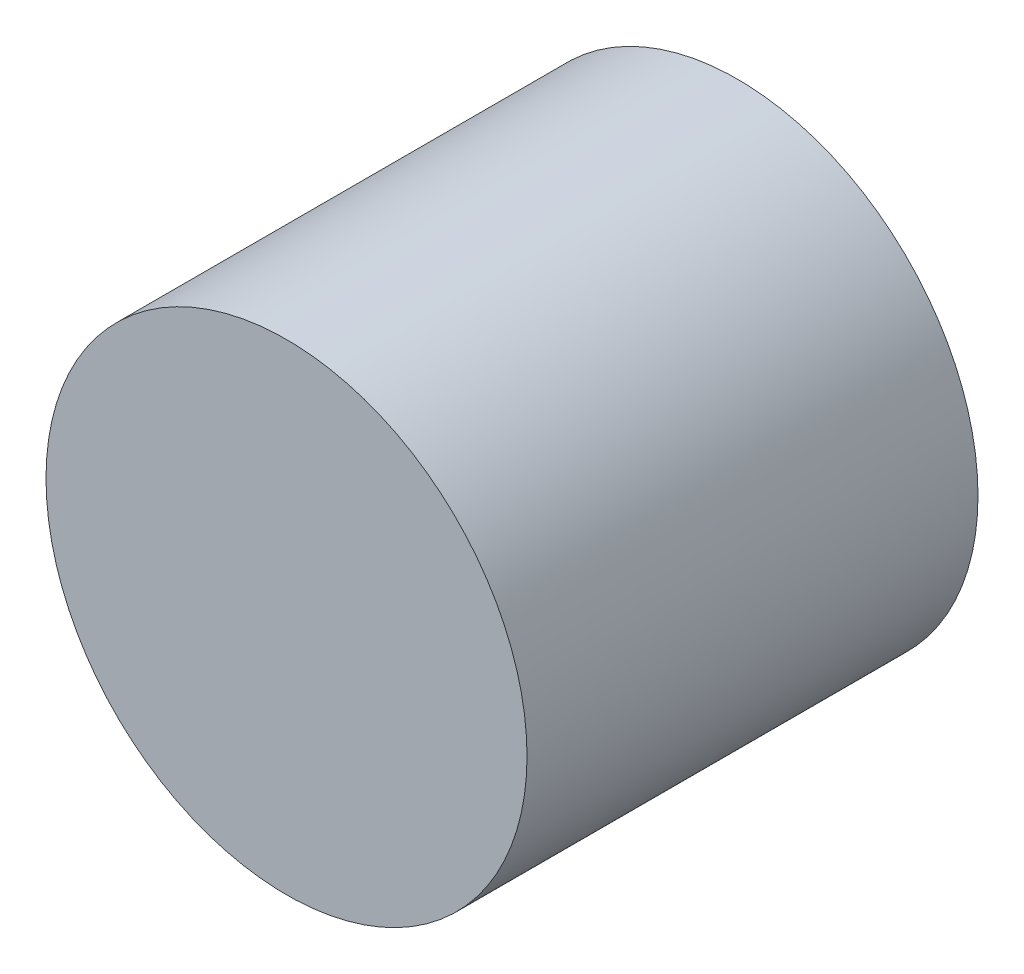
from build123d import *

# Parameters (mm, degrees)
ESQUISSE1_R        = 80
BOSS_EXTRU_1_DEPTH = 150


with BuildPart() as part:
    # Esquisse1 → Boss.-Extru.1 (new body)
    with BuildSketch(Plane.XY):
        Circle(ESQUISSE1_R)
    extrude(amount=BOSS_EXTRU_1_DEPTH)


solid = part.part
